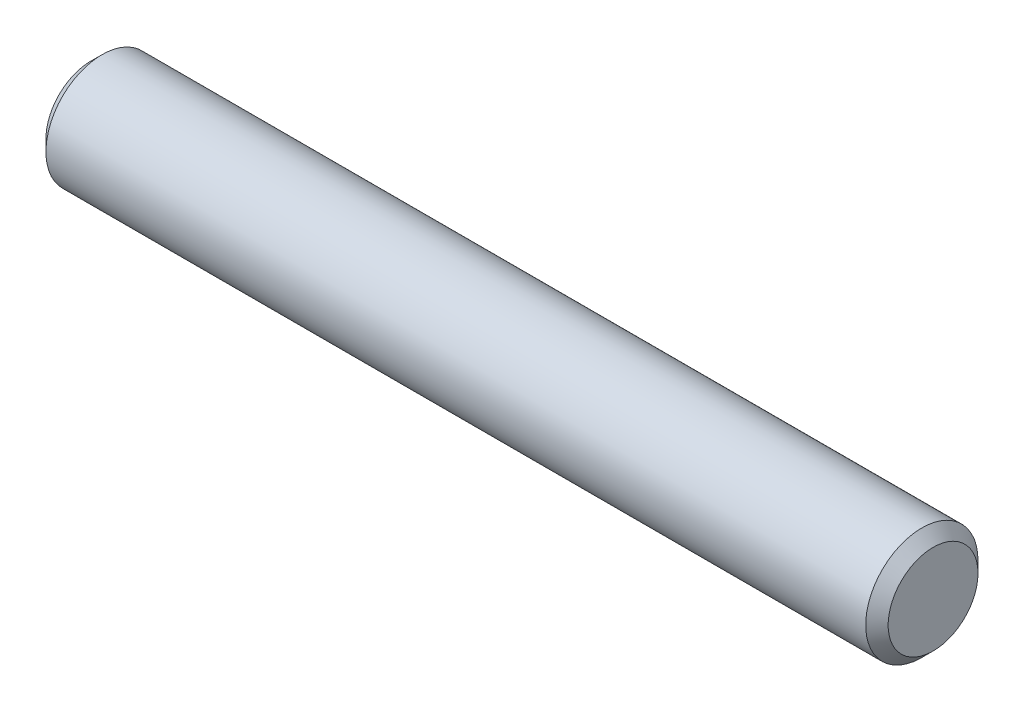
from build123d import *

# Parameters (mm, degrees)
SKETCH2_R           = 3.175
EXTRUDE1_DEPTH      = 23.8125
EXTRUDE1_DEPTH_BACK = 23.8125
CHAMFER1_SIZE       = 0.635


with BuildPart() as part:
    # Sketch2 → Extrude1 (new body, two sides)
    with BuildSketch(Plane(origin=(0, 0, 0), x_dir=(0, 0, -1), z_dir=(1, 0, 0))) as extrude1_sk:
        Circle(SKETCH2_R)
    extrude(amount=EXTRUDE1_DEPTH)
    extrude(extrude1_sk.sketch, amount=-EXTRUDE1_DEPTH_BACK)

    # Chamfer1
    chamfer1_edges = [part.edges().sort_by_distance(p)[0] for p in [
        (-23.8125, 0, 3.175),
        (23.8125, 0, 3.175),
    ]]
    chamfer(chamfer1_edges, length=CHAMFER1_SIZE)


solid = part.part
